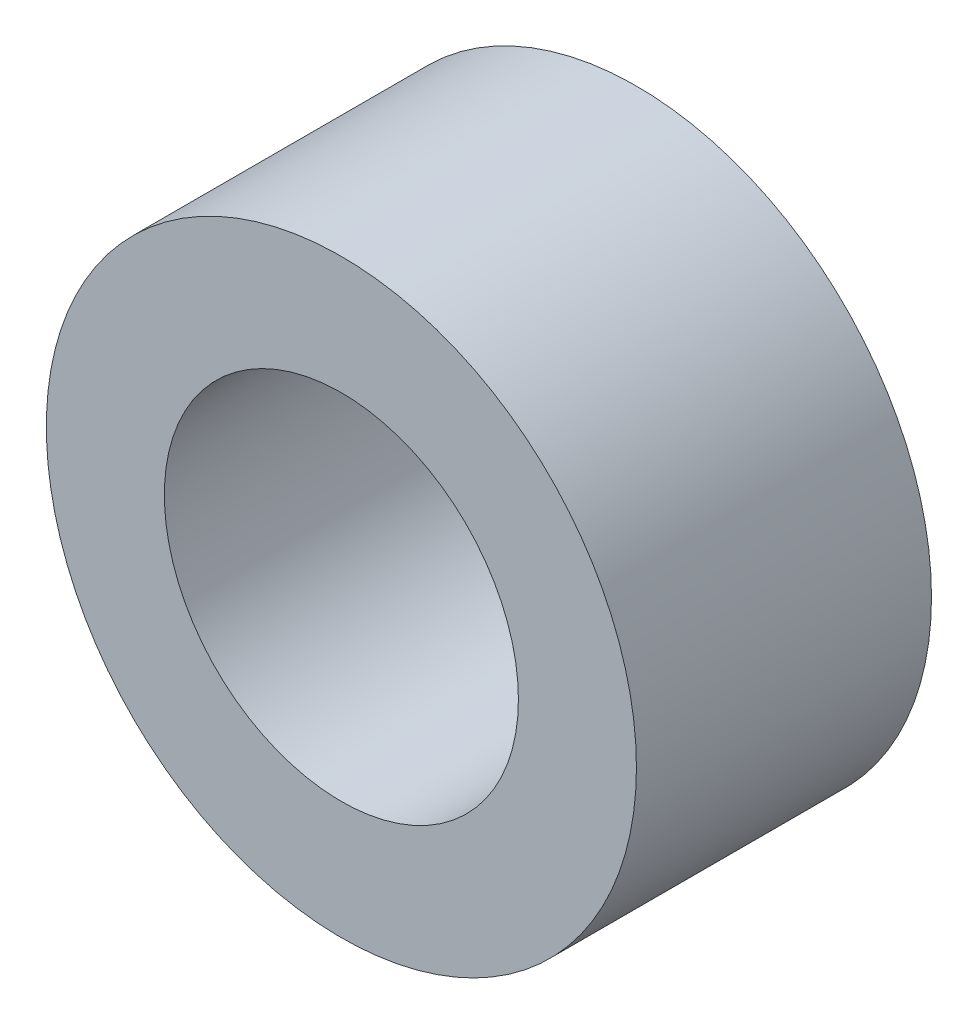
from build123d import *

# Parameters (mm, degrees)
ESQUISSE1_R        = 2
ESQUISSE1_R_2      = 1.2
BOSS_EXTRU_1_DEPTH = 2


with BuildPart() as part:
    # Esquisse1 → Boss.-Extru.1 (new body)
    with BuildSketch(Plane.XY):
        Circle(ESQUISSE1_R)
        Circle(ESQUISSE1_R_2, mode=Mode.SUBTRACT)
    extrude(amount=BOSS_EXTRU_1_DEPTH)


solid = part.part
